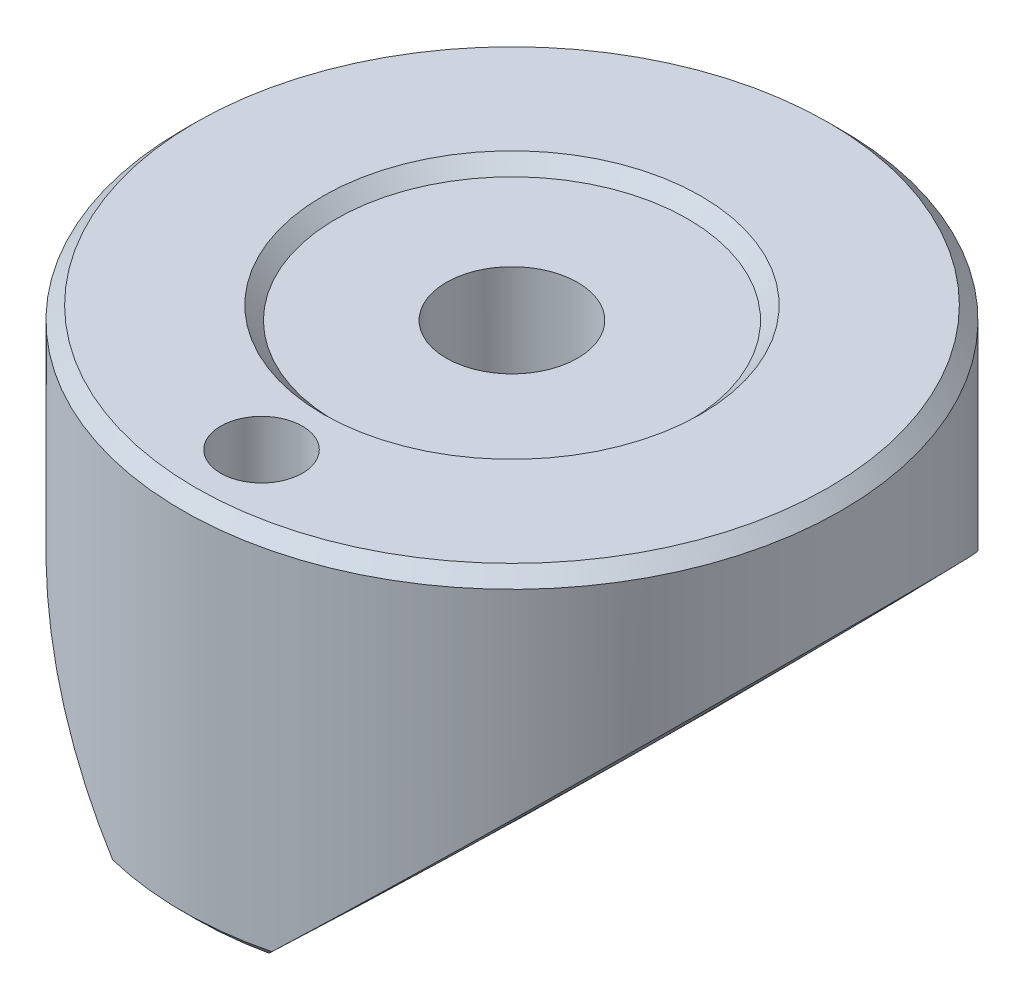
from build123d import *

# Parameters (mm, degrees)
SKETCH3_W                  = 9.525
SKETCH3_H                  = 10.795
SKETCH10_R                 = 1.1811
CUT_EXTRUDE1_DEPTH         = 17.51
CHAMFER1_SIZE              = 0.381
F_10_24_TAPPED_HOLE1_D     = 3.7973
F_10_24_TAPPED_HOLE1_DEPTH = 6.35
F_10_24_TAPPED_HOLE1_TIP   = 1.140824014


with BuildPart() as part:
    # Sketch3 → Revolve1 (revolve)
    with BuildSketch(Plane.XY, mode=Mode.PRIVATE) as revolve1_sk:
        with Locations((-4.7625, 11.1125)):
            Rectangle(SKETCH3_W, SKETCH3_H)
    revolve(revolve1_sk.sketch.rotate(Axis((0, 5.715, 0), (0, 1, 0)), 180), axis=Axis((0, 5.715, 0), (0, 1, 0)))  # turned: the seam where the file's is

    # Sketch10 → Cut-Extrude1 (cut, through all)
    with BuildSketch(Plane(origin=(0, 0, 0), x_dir=(1, 0, 0), z_dir=(0, 1, 0))):
        with Locations(Location((0, -7.239, 0), (0, 0, 180))):  # turned: the seam where the file's is
            Circle(SKETCH10_R)
    extrude(amount=CUT_EXTRUDE1_DEPTH, mode=Mode.SUBTRACT)

    # Chamfer1
    chamfer1_edges = [part.edges().sort_by_distance(p)[0] for p in [
        (-9.525, 16.51, 0),
        (-9.525, 5.715, 0),
    ]]
    chamfer(chamfer1_edges, length=CHAMFER1_SIZE)

    # #10-24 Tapped Hole1
    with Locations(Plane(origin=(0, 16.51, 0), x_dir=(1, 0, 0), z_dir=(0, 1, 0))):
        with Locations((0, 0)):
            Hole(F_10_24_TAPPED_HOLE1_D / 2, depth=F_10_24_TAPPED_HOLE1_DEPTH)
            with Locations((0, 0, -(F_10_24_TAPPED_HOLE1_DEPTH + F_10_24_TAPPED_HOLE1_TIP / 2))):  # 118° drill point
                Cone(0, F_10_24_TAPPED_HOLE1_D / 2, F_10_24_TAPPED_HOLE1_TIP, mode=Mode.SUBTRACT)

    # Sketch15 → Cut-Revolve3 (revolve, cut)
    with BuildSketch(Plane.XY):
        with BuildLine():
            Line((-11.578836277, 15.257357798), (-11.578836277, 2.536311926))
            Line((-11.578836277, 2.536311926), (1.226518223, 2.536311926))
            ThreePointArc((1.226518223, 2.536311926), (-5.290998219, 8.781234574), (-11.578836277, 15.257357798))
        make_face()
    cut_revolve3 = revolve(axis=Axis((170.909475954, 186.149475954, 0), (0, -1, 0)), mode=Mode.SUBTRACT)

    # Mirror2: Cut-Revolve3 across plane
    add(cut_revolve3.mirror(Plane(origin=(0, 0, 0), x_dir=(0, 0, 1), z_dir=(1, 0, 0))), mode=Mode.SUBTRACT)

    # Sketch16 → Cut-Revolve4 (revolve, cut)
    with BuildSketch(Plane.XY):
        Polygon((0, 16.999184369), (0, 16.129), (5.08, 16.129), (6.340889503, 17.389889503), align=None)
    revolve(axis=Axis((0, 0, 0), (0, 1, 0)), mode=Mode.SUBTRACT)


solid = part.part
